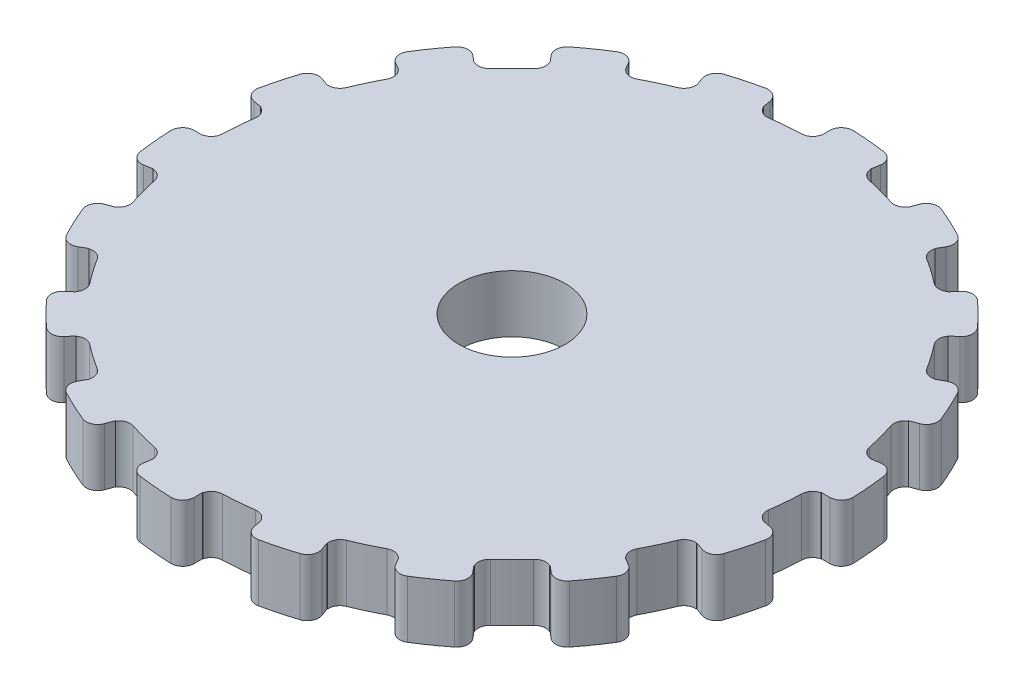
from build123d import *

# Parameters (mm, degrees)
CROQUIS1_R              = 3.7
SALIENTE_EXTRUIR1_DEPTH = 4
CORTAR_EXTRUIR2_START   = -4
CORTAR_EXTRUIR2_DEPTH   = 4
MATRIZC1_COUNT          = 18
ESCALA1_SCALE           = 0.99


with BuildPart() as part:
    # Croquis1 → Saliente-Extruir1 (new body)
    with BuildSketch(Plane(origin=(0, 0, 0), x_dir=(1, 0, 0), z_dir=(0, 1, 0))):
        with BuildLine():
            Line((3.750800638, 21.271847465), (4.167556264, 23.635386072))
            ThreePointArc((4.167556264, 23.635386072), (2.091737826, 23.908672754), (0, 24))
            Line((0, 24), (0, 21.6))
            ThreePointArc((0, 21.6), (-1.882564043, 21.517805479), (-3.750800638, 21.271847465))
            Line((-3.750800638, 21.271847465), (-4.167556264, 23.635386072))
            ThreePointArc((-4.167556264, 23.635386072), (-6.211657082, 23.182219831), (-8.20848344, 22.552622899))
            Line((-8.20848344, 22.552622899), (-7.387635096, 20.297360609))
            ThreePointArc((-7.387635096, 20.297360609), (-9.128554454, 19.5762482), (-10.8, 18.706148722))
            Line((-10.8, 18.706148722), (-12, 20.784609691))
            ThreePointArc((-12, 20.784609691), (-13.765834472, 19.659649063), (-15.426902632, 18.385066635))
            Line((-15.426902632, 18.385066635), (-13.884212369, 16.546559971))
            ThreePointArc((-13.884212369, 16.546559971), (-15.273506474, 15.273506474), (-16.546559971, 13.884212369))
            Line((-16.546559971, 13.884212369), (-18.385066635, 15.426902632))
            ThreePointArc((-18.385066635, 15.426902632), (-19.659649063, 13.765834472), (-20.784609691, 12))
            Line((-20.784609691, 12), (-18.706148722, 10.8))
            ThreePointArc((-18.706148722, 10.8), (-19.5762482, 9.128554454), (-20.297360609, 7.387635096))
            Line((-20.297360609, 7.387635096), (-22.552622899, 8.20848344))
            ThreePointArc((-22.552622899, 8.20848344), (-23.182219831, 6.211657082), (-23.635386072, 4.167556264))
            Line((-23.635386072, 4.167556264), (-21.271847465, 3.750800638))
            ThreePointArc((-21.271847465, 3.750800638), (-21.517805479, 1.882564043), (-21.6, 0))
            Line((-21.6, 0), (-24, 0))
            ThreePointArc((-24, 0), (-23.908672754, -2.091737826), (-23.635386072, -4.167556264))
            Line((-23.635386072, -4.167556264), (-21.271847465, -3.750800638))
            ThreePointArc((-21.271847465, -3.750800638), (-20.863997848, -5.590491374), (-20.297360609, -7.387635096))
            Line((-20.297360609, -7.387635096), (-22.552622899, -8.20848344))
            ThreePointArc((-22.552622899, -8.20848344), (-21.751386889, -10.142838282), (-20.784609691, -12))
            Line((-20.784609691, -12), (-18.706148722, -10.8))
            ThreePointArc((-18.706148722, -10.8), (-17.693684157, -12.389251025), (-16.546559971, -13.884212369))
            Line((-16.546559971, -13.884212369), (-18.385066635, -15.426902632))
            ThreePointArc((-18.385066635, -15.426902632), (-16.970562748, -16.970562748), (-15.426902632, -18.385066635))
            Line((-15.426902632, -18.385066635), (-13.884212369, -16.546559971))
            ThreePointArc((-13.884212369, -16.546559971), (-12.389251025, -17.693684157), (-10.8, -18.706148722))
            Line((-10.8, -18.706148722), (-12, -20.784609691))
            ThreePointArc((-12, -20.784609691), (-10.142838282, -21.751386889), (-8.20848344, -22.552622899))
            Line((-8.20848344, -22.552622899), (-7.387635096, -20.297360609))
            ThreePointArc((-7.387635096, -20.297360609), (-5.590491374, -20.863997848), (-3.750800638, -21.271847465))
            Line((-3.750800638, -21.271847465), (-4.167556264, -23.635386072))
            ThreePointArc((-4.167556264, -23.635386072), (-2.091737826, -23.908672754), (0, -24))
            Line((0, -24), (0, -21.6))
            ThreePointArc((0, -21.6), (1.882564043, -21.517805479), (3.750800638, -21.271847465))
            Line((3.750800638, -21.271847465), (4.167556264, -23.635386072))
            ThreePointArc((4.167556264, -23.635386072), (6.211657082, -23.182219831), (8.20848344, -22.552622899))
            Line((8.20848344, -22.552622899), (7.387635096, -20.297360609))
            ThreePointArc((7.387635096, -20.297360609), (9.128554454, -19.5762482), (10.8, -18.706148722))
            Line((10.8, -18.706148722), (12, -20.784609691))
            ThreePointArc((12, -20.784609691), (13.765834472, -19.659649063), (15.426902632, -18.385066635))
            Line((15.426902632, -18.385066635), (13.884212369, -16.546559971))
            ThreePointArc((13.884212369, -16.546559971), (15.273506474, -15.273506474), (16.546559971, -13.884212369))
            Line((16.546559971, -13.884212369), (18.385066635, -15.426902632))
            ThreePointArc((18.385066635, -15.426902632), (19.659649063, -13.765834472), (20.784609691, -12))
            Line((20.784609691, -12), (18.706148722, -10.8))
            ThreePointArc((18.706148722, -10.8), (19.5762482, -9.128554454), (20.297360609, -7.387635096))
            Line((20.297360609, -7.387635096), (22.552622899, -8.20848344))
            ThreePointArc((22.552622899, -8.20848344), (23.182219831, -6.211657082), (23.635386072, -4.167556264))
            Line((23.635386072, -4.167556264), (21.271847465, -3.750800638))
            ThreePointArc((21.271847465, -3.750800638), (21.517805479, -1.882564043), (21.6, 0))
            Line((21.6, 0), (24, 0))
            ThreePointArc((24, 0), (23.908672754, 2.091737826), (23.635386072, 4.167556264))
            Line((23.635386072, 4.167556264), (21.271847465, 3.750800638))
            ThreePointArc((21.271847465, 3.750800638), (20.863997848, 5.590491374), (20.297360609, 7.387635096))
            Line((20.297360609, 7.387635096), (22.552622899, 8.20848344))
            ThreePointArc((22.552622899, 8.20848344), (21.751386889, 10.142838282), (20.784609691, 12))
            Line((20.784609691, 12), (18.706148722, 10.8))
            ThreePointArc((18.706148722, 10.8), (17.693684157, 12.389251025), (16.546559971, 13.884212369))
            Line((16.546559971, 13.884212369), (18.385066635, 15.426902632))
            ThreePointArc((18.385066635, 15.426902632), (16.970562748, 16.970562748), (15.426902632, 18.385066635))
            Line((15.426902632, 18.385066635), (13.884212369, 16.546559971))
            ThreePointArc((13.884212369, 16.546559971), (12.389251025, 17.693684157), (10.8, 18.706148722))
            Line((10.8, 18.706148722), (12, 20.784609691))
            ThreePointArc((12, 20.784609691), (10.142838282, 21.751386889), (8.20848344, 22.552622899))
            Line((8.20848344, 22.552622899), (7.387635096, 20.297360609))
            ThreePointArc((7.387635096, 20.297360609), (5.590491374, 20.863997848), (3.750800638, 21.271847465))
        make_face()
        Circle(CROQUIS1_R, mode=Mode.SUBTRACT)
    extrude(amount=SALIENTE_EXTRUIR1_DEPTH)

    # Croquis3 → Cortar-Extruir2 (cut)
    with BuildSketch(Plane(origin=(0, 4, 0), x_dir=(1, 0, 0), z_dir=(0, 1, 0)).offset(CORTAR_EXTRUIR2_START)):
        with BuildLine():
            ThreePointArc((3.175076951, 22.779791183), (3.711585598, 22.45804677), (3.852485694, 21.848532078))
            Line((3.852485694, 21.848532078), (4.167556264, 23.635386072))
            ThreePointArc((4.167556264, 23.635386072), (2.091737826, 23.908672754), (0, 24))
            Line((0, 24), (0, 22.185580903))
            ThreePointArc((0, 22.185580903), (0.244600623, 22.761368652), (0.828828829, 22.985061296))
            ThreePointArc((0.828828829, 22.985061296), (2.004582083, 22.912478056), (3.175076951, 22.779791183))
        make_face()
        with BuildLine():
            ThreePointArc((7.367181438, 20.304793465), (5.590491374, 20.863997848), (3.772230453, 21.268057678))
            ThreePointArc((3.772230453, 21.268057678), (3.963826364, 20.79432449), (4.403089895, 20.533212106))
            ThreePointArc((4.403089895, 20.533212106), (5.435199947, 20.284442352), (6.453418349, 19.983828252))
            ThreePointArc((6.453418349, 19.983828252), (6.964387918, 19.990326445), (7.367181438, 20.304793465))
        make_face()
    cortar_extruir2 = extrude(amount=CORTAR_EXTRUIR2_DEPTH, mode=Mode.SUBTRACT)

    # MatrizC1: Cortar-Extruir2 ×18 about axis
    matrizc1_axis = Axis((0, 4, 0), (0, -1, 0))
    for i in range(1, MATRIZC1_COUNT):
        add(cortar_extruir2.rotate(matrizc1_axis, i * 360 / MATRIZC1_COUNT), mode=Mode.SUBTRACT)


with BuildPart() as part_1:
    # Escala1: scaled about (0, 2, 0)
    add(part.part.scale(ESCALA1_SCALE).moved(Location((0, 0.02, 0))))


solid = part_1.part
